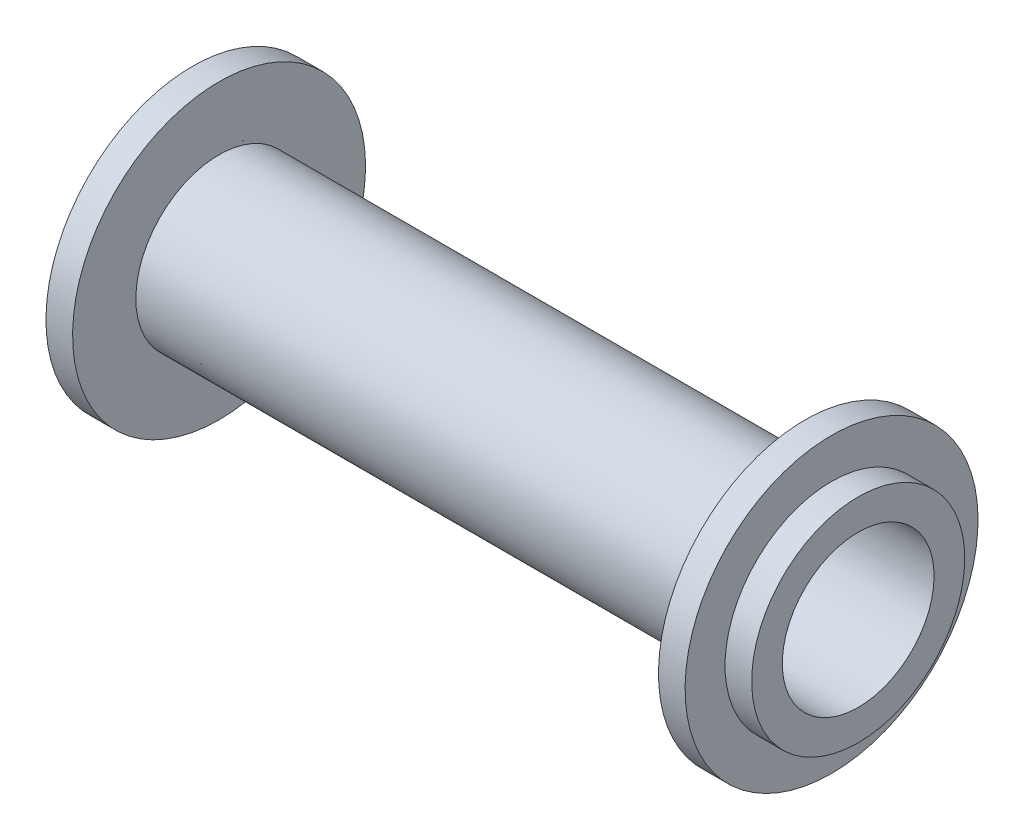
from build123d import *

# Parameters (mm, degrees)
SKETCH2_R           = 5.7
CUT_EXTRUDE1_DEPTH  = 51.457903246
SKETCH3_R           = 8
SKETCH3_R_2         = 5.7
BOSS_EXTRUDE1_DEPTH = 2
SKETCH4_R           = 8
SKETCH4_R_2         = 5.7
BOSS_EXTRUDE2_DEPTH = 2


with BuildPart() as part:
    # Sketch1 → Revolve1 (revolve)
    with BuildSketch(Plane.XY, mode=Mode.PRIVATE) as revolve1_sk:
        Polygon((-24, 0), (24, 0), (24, 11), (22, 11), (22, 6.25), (-22, 6.25), (-22, 11), (-24, 11), align=None)
    revolve(revolve1_sk.sketch.rotate(Axis((-24, 0, 0), (1, 0, 0)), 180), axis=Axis((-24, 0, 0), (1, 0, 0)))

    # Sketch2 → Cut-Extrude1 (cut, through all)
    with BuildSketch(Plane(origin=(24, 0, 0), x_dir=(0, 0, -1), z_dir=(1, 0, 0))):
        Circle(SKETCH2_R)
    extrude(amount=-CUT_EXTRUDE1_DEPTH, mode=Mode.SUBTRACT)

    # Sketch3 → Boss-Extrude1 (add)
    with BuildSketch(Plane(origin=(24, 0, 0), x_dir=(0, 0, -1), z_dir=(1, 0, 0))):
        with Locations(Location((0, 0, 0), (0, 0, 270))):
            Circle(SKETCH3_R)
        Circle(SKETCH3_R_2, mode=Mode.SUBTRACT)
    extrude(amount=BOSS_EXTRUDE1_DEPTH)

    # Sketch4 → Boss-Extrude2 (add)
    with BuildSketch(Plane.ZY.offset(24)):
        with Locations(Location((0, 0, 0), (0, 0, 270))):
            Circle(SKETCH4_R)
        with Locations(Location((0, 0, 0), (0, 0, 180))):
            Circle(SKETCH4_R_2, mode=Mode.SUBTRACT)
    extrude(amount=BOSS_EXTRUDE2_DEPTH)


solid = part.part
